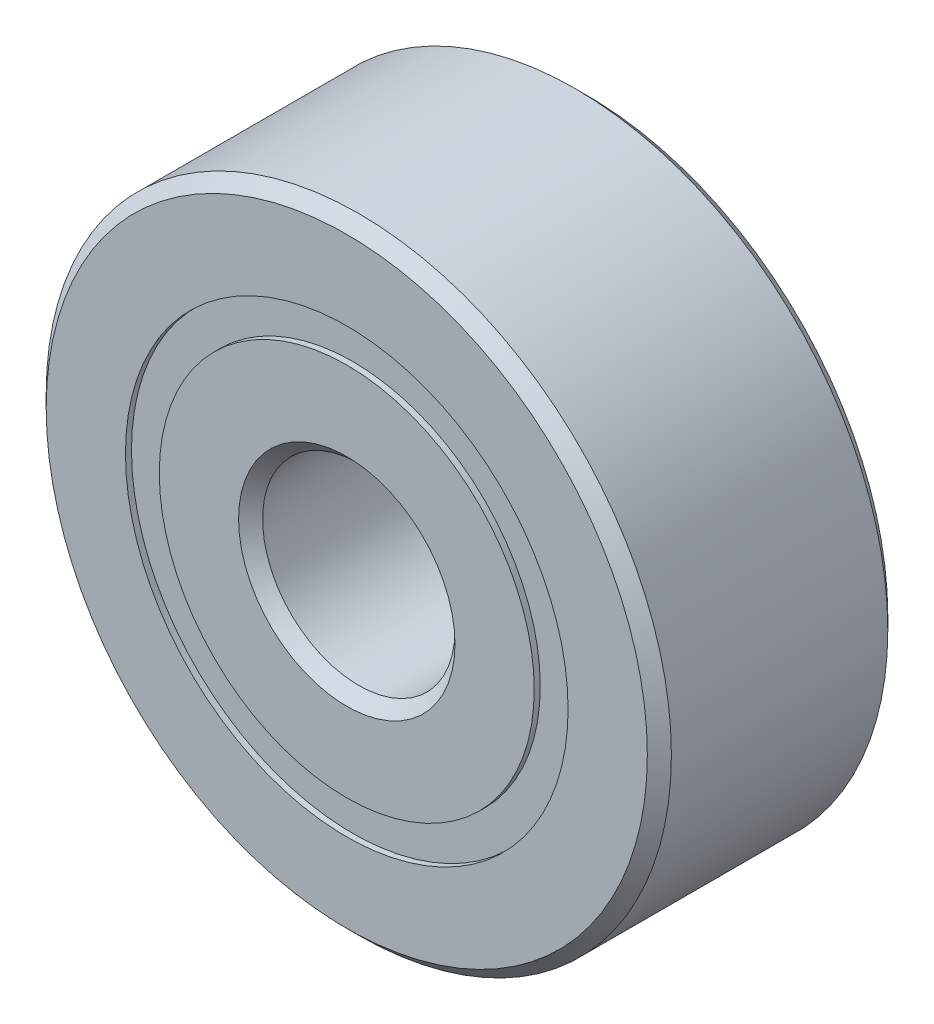
from build123d import *

# Parameters (mm, degrees)
CIRPATTERN1_COUNT = 12
SKETCH5_W         = 1.209571124
SKETCH5_H         = 0.703296704


with BuildPart() as part:
    # Sketch1 → Revolve1 (revolve)
    with BuildSketch(Plane(origin=(0, 0, 0), x_dir=(0, 0, -1), z_dir=(1, 0, 0))):
        with BuildLine():
            Line((2.25, 6.5), (-2.25, 6.5))
            Line((-2.25, 6.5), (-2.5, 6.25))
            Line((-2.5, 6.25), (-2.5, 4.601648352))
            Line((-2.5, 4.601648352), (-1.111111111, 4.601648352))
            ThreePointArc((-1.111111111, 4.601648352), (0, 5.415428876), (1.111111111, 4.601648352))
            Line((1.111111111, 4.601648352), (2.5, 4.601648352))
            Line((2.5, 4.601648352), (2.5, 6.25))
            Line((2.5, 6.25), (2.25, 6.5))
        make_face()
    revolve(axis=Axis((0, 0, 2.5), (0, 0, -1)))


with BuildPart() as body_2:
    # Sketch3 → Revolve3 (revolve)
    with BuildSketch(Plane(origin=(0, 0, 0), x_dir=(0, 0, -1), z_dir=(1, 0, 0))):
        with BuildLine():
            Line((-2.5, 3.898351648), (-1.111111111, 3.898351648))
            ThreePointArc((-1.111111111, 3.898351648), (0, 3.084571124), (1.111111111, 3.898351648))
            Line((1.111111111, 3.898351648), (2.5, 3.898351648))
            Line((2.5, 3.898351648), (2.5, 2.25))
            Line((2.5, 2.25), (2.25, 2))
            Line((2.25, 2), (-2.25, 2))
            Line((-2.25, 2), (-2.5, 2.25))
            Line((-2.5, 2.25), (-2.5, 3.898351648))
        make_face()
    revolve(axis=Axis((0, 0, 2.5), (0, 0, -1)))


with BuildPart() as body_3:
    # Sketch4 → Revolve4 (revolve)
    with BuildSketch(Plane(origin=(0, 0, 0), x_dir=(0, 0, -1), z_dir=(1, 0, 0))):
        with BuildLine():
            Line((-1.165428876, 4.25), (1.165428876, 4.25))
            ThreePointArc((1.165428876, 4.25), (0, 5.415428876), (-1.165428876, 4.25))
        make_face()
    revolve(axis=Axis((0, 4.25, 1.165428876), (0, 0, -1)))


with BuildPart() as cirpattern1_1:
    # CirPattern1: pattern copy
    add(body_3.part.rotate(Axis((0, 0, 0), (0, 0, 1)), 1 * 360 / CIRPATTERN1_COUNT))


with BuildPart() as cirpattern1_2:
    # CirPattern1: pattern copy
    add(body_3.part.rotate(Axis((0, 0, 0), (0, 0, 1)), 2 * 360 / CIRPATTERN1_COUNT))


with BuildPart() as cirpattern1_3:
    # CirPattern1: pattern copy
    add(body_3.part.rotate(Axis((0, 0, 0), (0, 0, 1)), 3 * 360 / CIRPATTERN1_COUNT))


with BuildPart() as cirpattern1_4:
    # CirPattern1: pattern copy
    add(body_3.part.rotate(Axis((0, 0, 0), (0, 0, 1)), 4 * 360 / CIRPATTERN1_COUNT))


with BuildPart() as cirpattern1_5:
    # CirPattern1: pattern copy
    add(body_3.part.rotate(Axis((0, 0, 0), (0, 0, 1)), 5 * 360 / CIRPATTERN1_COUNT))


with BuildPart() as cirpattern1_6:
    # CirPattern1: pattern copy
    add(body_3.part.rotate(Axis((0, 0, 0), (0, 0, 1)), 6 * 360 / CIRPATTERN1_COUNT))


with BuildPart() as cirpattern1_7:
    # CirPattern1: pattern copy
    add(body_3.part.rotate(Axis((0, 0, 0), (0, 0, 1)), 7 * 360 / CIRPATTERN1_COUNT))


with BuildPart() as cirpattern1_8:
    # CirPattern1: pattern copy
    add(body_3.part.rotate(Axis((0, 0, 0), (0, 0, 1)), 8 * 360 / CIRPATTERN1_COUNT))


with BuildPart() as cirpattern1_9:
    # CirPattern1: pattern copy
    add(body_3.part.rotate(Axis((0, 0, 0), (0, 0, 1)), 9 * 360 / CIRPATTERN1_COUNT))


with BuildPart() as cirpattern1_10:
    # CirPattern1: pattern copy
    add(body_3.part.rotate(Axis((0, 0, 0), (0, 0, 1)), 10 * 360 / CIRPATTERN1_COUNT))


with BuildPart() as cirpattern1_11:
    # CirPattern1: pattern copy
    add(body_3.part.rotate(Axis((0, 0, 0), (0, 0, 1)), 11 * 360 / CIRPATTERN1_COUNT))


with BuildPart() as body_15:
    # Sketch5 → Revolve5 (revolve)
    with BuildSketch(Plane(origin=(0, 0, 0), x_dir=(0, 0, -1), z_dir=(1, 0, 0))):
        with Locations((-1.770214438, 4.25)):
            Rectangle(SKETCH5_W, SKETCH5_H)
        with Locations((1.770214438, 4.25)):
            Rectangle(SKETCH5_W, SKETCH5_H)
    revolve(axis=Axis((0, 0, 2.5), (0, 0, -1)))


solid = Compound([part.part, body_2.part, body_3.part, cirpattern1_1.part, cirpattern1_2.part, cirpattern1_3.part, cirpattern1_4.part, cirpattern1_5.part, cirpattern1_6.part, cirpattern1_7.part, cirpattern1_8.part, cirpattern1_9.part, cirpattern1_10.part, cirpattern1_11.part, body_15.part])
